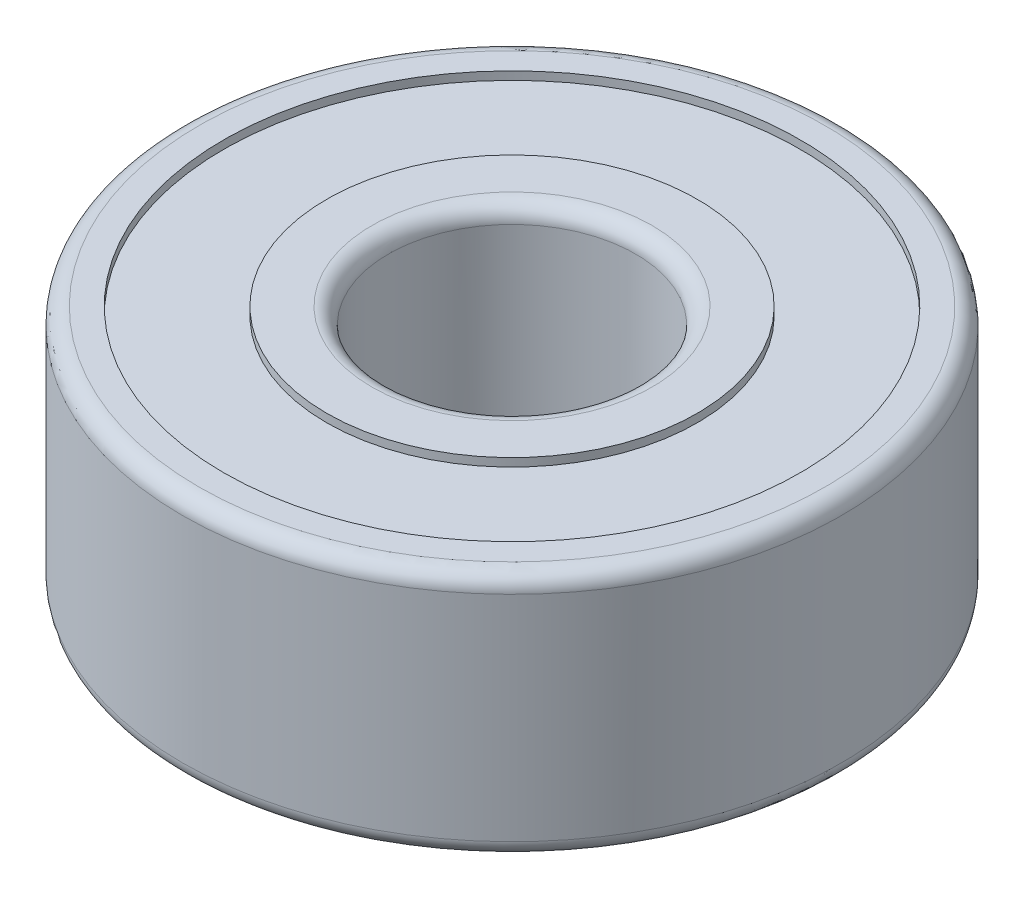
from build123d import *

# Parameters (mm, degrees)
FILLET1_R            = 0.2
FILLET1_OF_MIRROR1_R = 0.2


with BuildPart() as part:
    # Sketch1 → Revolve1 (revolve)
    with BuildSketch(Plane(origin=(0, 0, 0), x_dir=(0, 0, -1), z_dir=(1, 0, 0))):
        Polygon((-4, 1.5), (-3.5, 1.5), (-3.5, 1.4), (-2.25, 1.4), (-2.25, 1.5), (-1.5, 1.5), (-1.5, 0), (-4, 0), align=None)
    revolve1 = revolve(axis=Axis((0, 17.307692308, 0), (0, -1, 0)))

    # Fillet1
    fillet1_edges = [part.edges().sort_by_distance(p)[0] for p in [
        (0, 1.5, -4),
        (0, 1.5, -1.5),
    ]]
    fillet(fillet1_edges, radius=FILLET1_R)

    # Mirror1: Revolve1 across plane
    add(revolve1.mirror(Plane.ZX))

    # Fillet1 of Mirror1
    fillet1_of_mirror1_edges = [part.edges().sort_by_distance(p)[0] for p in [
        (0, -1.5, -4),
        (0, -1.5, -1.5),
    ]]
    fillet(fillet1_of_mirror1_edges, radius=FILLET1_OF_MIRROR1_R)


solid = part.part
